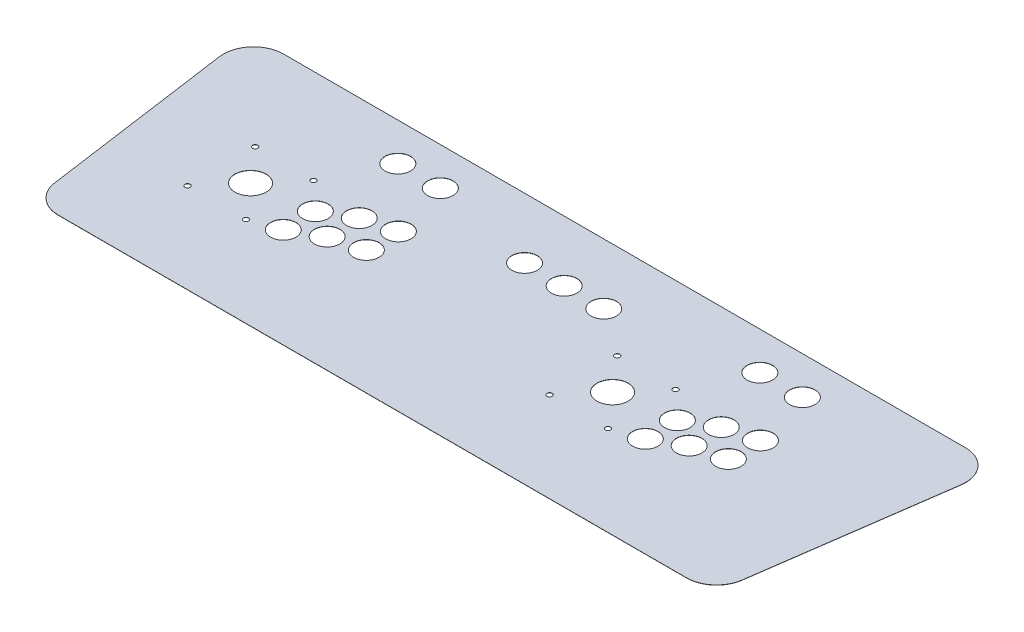
from build123d import *

# Parameters (mm, degrees)
SKETCH1_W               = 671.5125
SKETCH1_H               = 299.466
BOSS_EXTRUDE1_DEPTH     = 0.1016
BOSS_EXTRUDE2_DEPTH     = 0.2032
FILLET1_R               = 25.4
SKETCH3_R               = 17.5
SKETCH3_R_2             = 14.2875
SKETCH3_R_3             = 2.95
CUT_EXTRUDE1_DEPTH      = 1
CUT_EXTRUDE1_DEPTH_BACK = 1.2032
SKETCH4_W               = 671.5125
SKETCH4_H               = 33.0708508
CUT_EXTRUDE2_DEPTH      = 1
CUT_EXTRUDE2_DEPTH_BACK = 1.2032
BOSS_EXTRUDE3_DEPTH     = 0.2032


with BuildPart() as part:
    # Sketch1 → Boss-Extrude1 (new body, symmetric)
    with BuildSketch(Plane(origin=(0, 0, 0), x_dir=(1, 0, 0), z_dir=(0, 1, 0))):
        Rectangle(SKETCH1_W, SKETCH1_H)
    extrude(amount=BOSS_EXTRUDE1_DEPTH, both=True)

    # Sketch2 → Boss-Extrude2 (add)
    with BuildSketch(Plane(origin=(0, 0.1016, 0), x_dir=(1, 0, 0), z_dir=(0, 1, 0))):
        Polygon((335.75625, -149.733), (374.643853371, -149.733), (412.08325, 116.6621492), (335.75625, 116.6621492), align=None)
        Polygon((-335.75625, 116.6621492), (-335.75625, -149.733), (-374.643853371, -149.733), (-412.08325, 116.6621492), align=None)
    extrude(amount=-BOSS_EXTRUDE2_DEPTH)

    # Fillet1
    fillet1_edges = [part.edges().sort_by_distance(p)[0] for p in [
        (374.643853371, 0, 149.733),
        (412.08325, 0, -116.6621492),
        (-412.08325, 0, -116.6621492),
        (-374.643853371, 0, 149.733),
    ]]
    fillet(fillet1_edges, radius=FILLET1_R)

    # Sketch3 → Cut-Extrude1 (cut, two sides)
    with BuildSketch(Plane(origin=(0, 0.1016, 0), x_dir=(1, 0, 0), z_dir=(0, 1, 0))) as cut_extrude1_sk:
        with Locations((-275.836957508, -19.05)):
            Circle(SKETCH3_R)
        with Locations((-180.836957508, 7.95)):
            Circle(SKETCH3_R_2)
        with Locations((-145.836957508, 16.95)):
            Circle(SKETCH3_R_2)
        with Locations((-145.836957508, -19.05)):
            Circle(SKETCH3_R_2)
        with Locations((-180.836957508, -28.05)):
            Circle(SKETCH3_R_2)
        with Locations((-212.086957508, -10.05)):
            Circle(SKETCH3_R_2)
        with Locations((-212.086957508, -46.05)):
            Circle(SKETCH3_R_2)
        with Locations((-212.086957508, 82.55)):
            Circle(SKETCH3_R_2)
        with Locations((-164.36967051, 82.55)):
            Circle(SKETCH3_R_2)
        with Locations((130.563042492, -19.05)):
            Circle(SKETCH3_R)
        with Locations((225.563042492, 7.95)):
            Circle(SKETCH3_R_2)
        with Locations((260.563042492, 16.95)):
            Circle(SKETCH3_R_2)
        with Locations((260.563042492, -19.05)):
            Circle(SKETCH3_R_2)
        with Locations((225.563042492, -28.05)):
            Circle(SKETCH3_R_2)
        with Locations((194.313042492, -10.05)):
            Circle(SKETCH3_R_2)
        with Locations((194.313042492, -46.05)):
            Circle(SKETCH3_R_2)
        with Locations((194.313042492, 82.55)):
            Circle(SKETCH3_R_2)
        with Locations((242.03032949, 82.55)):
            Circle(SKETCH3_R_2)
        with Locations((-308.636957508, 18.9)):
            Circle(SKETCH3_R_3)
        with Locations((-243.036957508, 18.9)):
            Circle(SKETCH3_R_3)
        with Locations((-308.636957508, -57)):
            Circle(SKETCH3_R_3)
        with Locations((-243.036957508, -57)):
            Circle(SKETCH3_R_3)
        with Locations((97.763042492, 18.9)):
            Circle(SKETCH3_R_3)
        with Locations((163.363042492, 18.9)):
            Circle(SKETCH3_R_3)
        with Locations((97.763042492, -57)):
            Circle(SKETCH3_R_3)
        with Locations((163.363042492, -57)):
            Circle(SKETCH3_R_3)
        with Locations((-44.45, 57.15)):
            Circle(SKETCH3_R_2)
        with Locations((0, 57.15)):
            Circle(SKETCH3_R_2)
        with Locations((44.45, 57.15)):
            Circle(SKETCH3_R_2)
    extrude(amount=CUT_EXTRUDE1_DEPTH, mode=Mode.SUBTRACT)
    extrude(cut_extrude1_sk.sketch, amount=-CUT_EXTRUDE1_DEPTH_BACK, mode=Mode.SUBTRACT)

    # Sketch4 → Cut-Extrude2 (cut, two sides)
    with BuildSketch(Plane(origin=(0, 0.1016, 0), x_dir=(1, 0, 0), z_dir=(0, 1, 0))) as cut_extrude2_sk:
        with Locations((0, 133.1975746)):
            Rectangle(SKETCH4_W, SKETCH4_H)
    extrude(amount=CUT_EXTRUDE2_DEPTH, mode=Mode.SUBTRACT)
    extrude(cut_extrude2_sk.sketch, amount=-CUT_EXTRUDE2_DEPTH_BACK, mode=Mode.SUBTRACT)

    # Sketch5 → Boss-Extrude3 (add)
    with BuildSketch(Plane(origin=(0, 0.1016, 0), x_dir=(1, 0, 0), z_dir=(0, 1, 0))):
        with BuildLine():
            Line((382.863892457, 124.9679492), (-382.863892457, 124.9679492))
            ThreePointArc((-382.863892457, 124.9679492), (-408.301982626, 113.375143619), (-416.241669928, 86.571208494))
            Line((-416.241669928, 86.571208494), (-385.941747702, -129.023940706))
            ThreePointArc((-385.941747702, -129.023940706), (-374.67696465, -149.771090169), (-352.56397023, -158.0388))
            Line((-352.56397023, -158.0388), (352.56397023, -158.0388))
            ThreePointArc((352.56397023, -158.0388), (374.67696465, -149.771090169), (385.941747702, -129.023940706))
            Line((385.941747702, -129.023940706), (416.241669928, 86.571208494))
            ThreePointArc((416.241669928, 86.571208494), (408.301982626, 113.375143619), (382.863892457, 124.9679492))
        make_face()
        with BuildLine():
            Line((382.863892457, 116.6621492), (-382.863892457, 116.6621492))
            ThreePointArc((-382.863892457, 116.6621492), (-402.033515794, 107.926048536), (-408.016701403, 87.727152436))
            Line((-408.016701403, 87.727152436), (-377.716779176, -127.867996764))
            ThreePointArc((-377.716779176, -127.867996764), (-369.227869567, -143.502623338), (-352.56397023, -149.733))
            Line((-352.56397023, -149.733), (352.56397023, -149.733))
            ThreePointArc((352.56397023, -149.733), (369.227869567, -143.502623338), (377.716779176, -127.867996764))
            Line((377.716779176, -127.867996764), (408.016701403, 87.727152436))
            ThreePointArc((408.016701403, 87.727152436), (402.033515794, 107.926048536), (382.863892457, 116.6621492))
        make_face(mode=Mode.SUBTRACT)
    extrude(amount=-BOSS_EXTRUDE3_DEPTH)


solid = part.part
